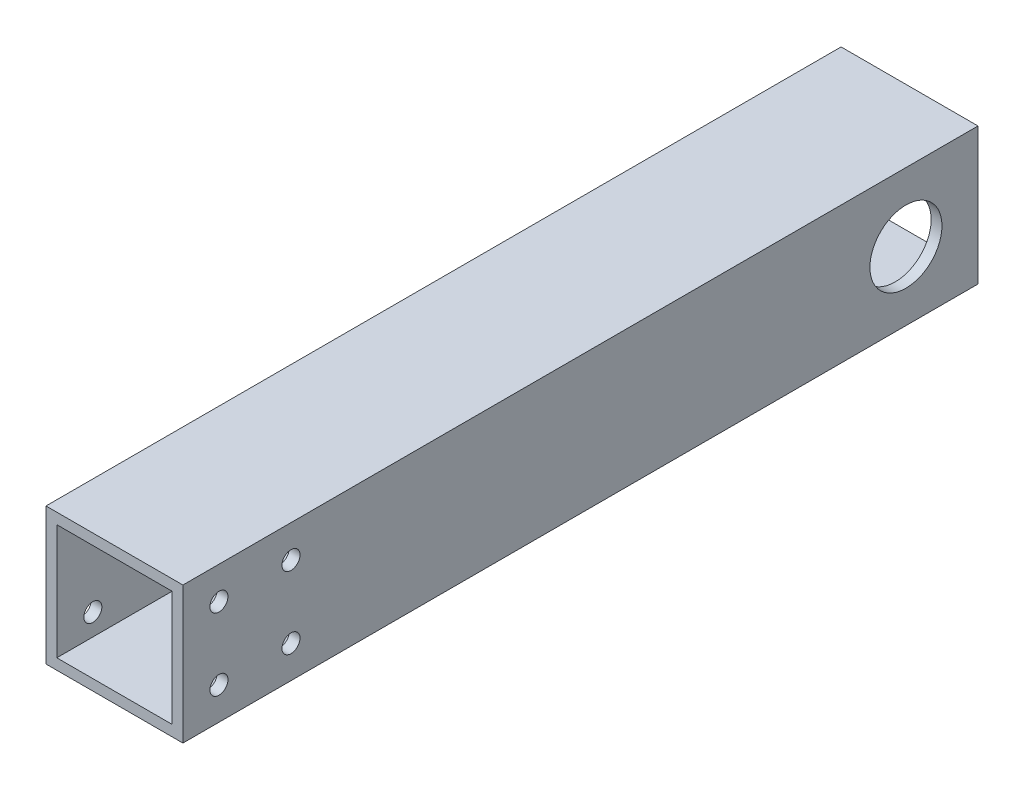
from build123d import *

# Parameters (mm, degrees)
SKETCH1_W               = 38
SKETCH1_H               = 38
SKETCH1_W_2             = 32
SKETCH1_H_2             = 32
BOSS_EXTRUDE1_DEPTH     = 220.68
SKETCH2_R               = 2.5
CUT_EXTRUDE1_DEPTH      = 1
CUT_EXTRUDE1_DEPTH_BACK = 39
SKETCH3_R               = 10
CUT_EXTRUDE2_DEPTH      = 39


with BuildPart() as part:
    # Sketch1 → Boss-Extrude1 (new body)
    with BuildSketch(Plane.XY):
        Rectangle(SKETCH1_W, SKETCH1_H)
        Rectangle(SKETCH1_W_2, SKETCH1_H_2, mode=Mode.SUBTRACT)
    extrude(amount=BOSS_EXTRUDE1_DEPTH)

    # Sketch2 → Cut-Extrude1 (cut, two sides)
    with BuildSketch(Plane.ZY.offset(19)) as cut_extrude1_sk:
        with Locations((190.68, -10)):
            Circle(SKETCH2_R)
        with Locations((210.68, -10)):
            Circle(SKETCH2_R)
        with Locations((190.68, 10)):
            Circle(SKETCH2_R)
        with Locations((210.68, 10)):
            Circle(SKETCH2_R)
    extrude(amount=CUT_EXTRUDE1_DEPTH, mode=Mode.SUBTRACT)
    extrude(cut_extrude1_sk.sketch, amount=-CUT_EXTRUDE1_DEPTH_BACK, mode=Mode.SUBTRACT)

    # Sketch3 → Cut-Extrude2 (cut, through all)
    with BuildSketch(Plane(origin=(19, 0, 0), x_dir=(0, 0, -1), z_dir=(1, 0, 0))):
        with Locations((-20, 0)):
            Circle(SKETCH3_R)
    extrude(amount=-CUT_EXTRUDE2_DEPTH, mode=Mode.SUBTRACT)


solid = part.part
